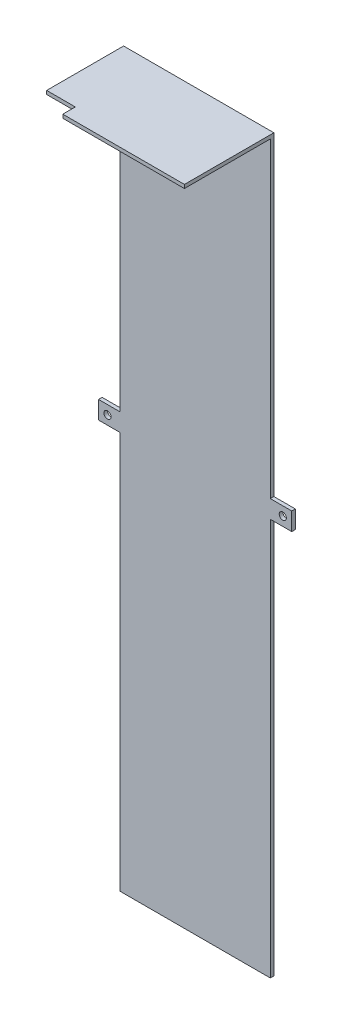
from build123d import *

# Parameters (mm, degrees)
SKETCH1_W            = 42
SKETCH1_H            = 25
BOSS_EXTRUDE1_DEPTH  = 1
SKETCH2_W            = 42
SKETCH2_H            = 1
BOSS_EXTRUDE2_DEPTH  = 179
SKETCH3_W            = 42
SKETCH3_H            = 1
BOSS_EXTRUDE3_DEPTH  = 2.1
SKETCH4_W            = 42
SKETCH4_H            = 1
BOSS_EXTRUDE4_DEPTH  = 15
SKETCH6_R            = 1.25
CUT_EXTRUDE1_DEPTH   = 15
SKETCH7_W            = 42
SKETCH7_H            = 1.67
CUT_EXTRUDE2_DEPTH   = 15
SKETCH8_W            = 8
SKETCH8_H            = 3.5
CUT_EXTRUDE3_DEPTH   = 15
SKETCH9_W            = 42
SKETCH9_H            = 14.33
CUT_EXTRUDE4_DEPTH   = 10
SKETCH10_W           = 5
SKETCH10_H           = 6
BOSS_EXTRUDE5_DEPTH  = 1
SKETCH11_R           = 1
CUT_EXTRUDE5_DEPTH   = 1
SKETCH12_W           = 42
SKETCH12_H           = 1
BOSS_EXTRUDE6_DEPTH  = 9
SKETCH13_W           = 5
SKETCH13_H           = 6
BOSS_EXTRUDE8_DEPTH  = 1
SKETCH15_R           = 1
CUT_EXTRUDE7_DEPTH   = 1
SKETCH16_W           = 6
SKETCH16_H           = 5
BOSS_EXTRUDE9_DEPTH  = 1
SKETCH17_W           = 53
SKETCH17_H           = 5
BOSS_EXTRUDE10_DEPTH = 1
SKETCH18_R           = 1
CUT_EXTRUDE8_DEPTH   = 1
SKETCH20_W           = 1
SKETCH20_H           = 5
BOSS_EXTRUDE11_DEPTH = 1
SKETCH21_R           = 1
CUT_EXTRUDE9_DEPTH   = 1
SKETCH22_W           = 42
SKETCH22_H           = 1
BOSS_EXTRUDE13_DEPTH = 24


with BuildPart() as part:
    # Sketch1 → Boss-Extrude1 (new body)
    with BuildSketch(Plane(origin=(0, 0, 0), x_dir=(1, 0, 0), z_dir=(0, 1, 0))):
        with Locations((4.315789474, -6.763157895)):
            Rectangle(SKETCH1_W, SKETCH1_H)
    extrude(amount=BOSS_EXTRUDE1_DEPTH)

    # Sketch2 → Boss-Extrude2 (add)
    with BuildSketch(Plane(origin=(0, 1, 0), x_dir=(1, 0, 0), z_dir=(0, 1, 0))):
        with Locations((4.315789474, 5.236842105)):
            Rectangle(SKETCH2_W, SKETCH2_H)
    extrude(amount=-BOSS_EXTRUDE2_DEPTH)

    # Sketch3 → Boss-Extrude3 (add)
    with BuildSketch(Plane.XZ.offset(178)):
        with Locations((4.315789474, -5.236842105)):
            Rectangle(SKETCH3_W, SKETCH3_H)
    extrude(amount=BOSS_EXTRUDE3_DEPTH)

    # Sketch4 → Boss-Extrude4 (add)
    with BuildSketch(Plane.XY.offset(-4.736842105)):
        with Locations((4.315789474, -179.6)):
            Rectangle(SKETCH4_W, SKETCH4_H)
    extrude(amount=BOSS_EXTRUDE4_DEPTH)

    # Sketch6 → Cut-Extrude1 (cut)
    with BuildSketch(Plane.XZ.offset(180.1)):
        with Locations((-6.684210526, 3.593157895)):
            Circle(SKETCH6_R)
        with Locations((15.315789474, 3.593157895)):
            Circle(SKETCH6_R)
    extrude(amount=-CUT_EXTRUDE1_DEPTH, mode=Mode.SUBTRACT)

    # Sketch7 → Cut-Extrude2 (cut)
    with BuildSketch(Plane.XZ.offset(180.1)):
        with Locations((4.315789474, 9.428157895)):
            Rectangle(SKETCH7_W, SKETCH7_H)
    extrude(amount=-CUT_EXTRUDE2_DEPTH, mode=Mode.SUBTRACT)

    # Sketch8 → Cut-Extrude3 (cut)
    with BuildSketch(Plane(origin=(0, 1, 0), x_dir=(1, 0, 0), z_dir=(0, 1, 0))):
        with Locations((-12.684210526, -17.513157895)):
            Rectangle(SKETCH8_W, SKETCH8_H)
    extrude(amount=-CUT_EXTRUDE3_DEPTH, mode=Mode.SUBTRACT)

    # Sketch9 → Cut-Extrude4 (cut)
    with BuildSketch(Plane.XZ.offset(180.1)):
        with Locations((4.315789474, 1.428157895)):
            Rectangle(SKETCH9_W, SKETCH9_H)
    extrude(amount=-CUT_EXTRUDE4_DEPTH, mode=Mode.SUBTRACT)

    # Sketch10 → Boss-Extrude5 (add)
    with BuildSketch(Plane(origin=(0, 0, -5.736842105), x_dir=(-1, 0, 0), z_dir=(0, 0, -1))):
        with Locations((-4.315789474, -173.1)):
            Rectangle(SKETCH10_W, SKETCH10_H)
    extrude(amount=-BOSS_EXTRUDE5_DEPTH)

    # Sketch11 → Cut-Extrude5 (cut)
    with BuildSketch(Plane(origin=(0, 0, -5.736842105), x_dir=(-1, 0, 0), z_dir=(0, 0, -1))):
        with Locations((-4.315789474, -173.6)):
            Circle(SKETCH11_R)
    extrude(amount=-CUT_EXTRUDE5_DEPTH, mode=Mode.SUBTRACT)

    # Sketch12 → Boss-Extrude6 (add)
    with BuildSketch(Plane.XZ.offset(170.1)):
        with Locations((4.315789474, -5.236842105)):
            Rectangle(SKETCH12_W, SKETCH12_H)
    extrude(amount=BOSS_EXTRUDE6_DEPTH)

    # Sketch13 → Boss-Extrude8 (add)
    with BuildSketch(Plane(origin=(0, 0, -5.736842105), x_dir=(-1, 0, 0), z_dir=(0, 0, -1))):
        with Locations((-4.315789474, -182.1)):
            Rectangle(SKETCH13_W, SKETCH13_H)
    extrude(amount=-BOSS_EXTRUDE8_DEPTH)

    # Sketch15 → Cut-Extrude7 (cut)
    with BuildSketch(Plane(origin=(0, 0, -5.736842105), x_dir=(-1, 0, 0), z_dir=(0, 0, -1))):
        with Locations((-4.315789474, -182.6)):
            Circle(SKETCH15_R)
    extrude(amount=-CUT_EXTRUDE7_DEPTH, mode=Mode.SUBTRACT)

    # Sketch16 → Boss-Extrude9 (add)
    with BuildSketch(Plane(origin=(0, 0, -5.736842105), x_dir=(-1, 0, 0), z_dir=(0, 0, -1))):
        with Locations((-28.315789474, -89.55)):
            Rectangle(SKETCH16_W, SKETCH16_H)
    extrude(amount=-BOSS_EXTRUDE9_DEPTH)

    # Sketch17 → Boss-Extrude10 (add)
    with BuildSketch(Plane(origin=(0, 0, -5.736842105), x_dir=(-1, 0, 0), z_dir=(0, 0, -1))):
        with Locations((-4.815789474, -89.55)):
            Rectangle(SKETCH17_W, SKETCH17_H)
    extrude(amount=-BOSS_EXTRUDE10_DEPTH)

    # Sketch18 → Cut-Extrude8 (cut)
    with BuildSketch(Plane(origin=(0, 0, -5.736842105), x_dir=(-1, 0, 0), z_dir=(0, 0, -1))):
        with Locations((-28.815789474, -89.55)):
            Circle(SKETCH18_R)
    extrude(amount=-CUT_EXTRUDE8_DEPTH, mode=Mode.SUBTRACT)

    # Sketch20 → Boss-Extrude11 (add)
    with BuildSketch(Plane.ZY.offset(21.684210526)):
        with Locations((-5.236842105, -89.55)):
            Rectangle(SKETCH20_W, SKETCH20_H)
    extrude(amount=BOSS_EXTRUDE11_DEPTH)

    # Sketch21 → Cut-Extrude9 (cut)
    with BuildSketch(Plane(origin=(0, 0, -5.736842105), x_dir=(-1, 0, 0), z_dir=(0, 0, -1))):
        with Locations((20.184210526, -89.55)):
            Circle(SKETCH21_R)
    extrude(amount=-CUT_EXTRUDE9_DEPTH, mode=Mode.SUBTRACT)

    # Sketch22 → Boss-Extrude13 (add)
    with BuildSketch(Plane.XZ.offset(179.1)):
        with Locations((4.315789474, -5.236842105)):
            Rectangle(SKETCH22_W, SKETCH22_H)
    extrude(amount=BOSS_EXTRUDE13_DEPTH)


solid = part.part
